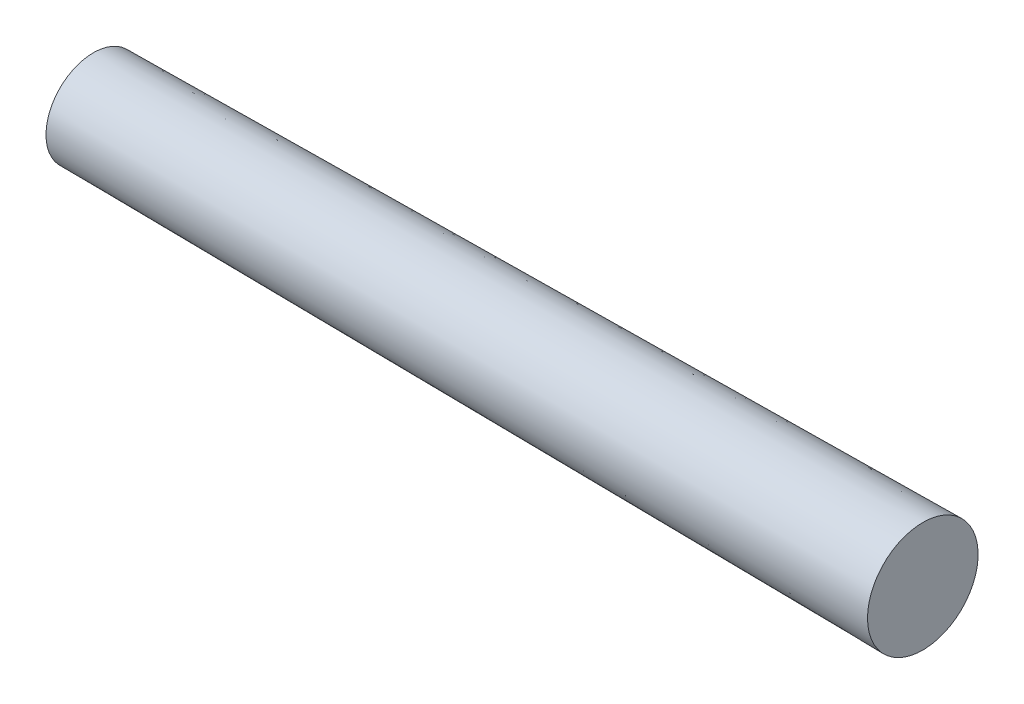
from build123d import *


with BuildPart() as part:
    # Sketch1 → Revolve1 (revolve)
    with BuildSketch(Plane.XY):
        Polygon((0, 0), (0, 6), (105, 7), (105, 0), align=None)
    revolve(axis=Axis((0, 0, 0), (1, 0, 0)))


solid = part.part
